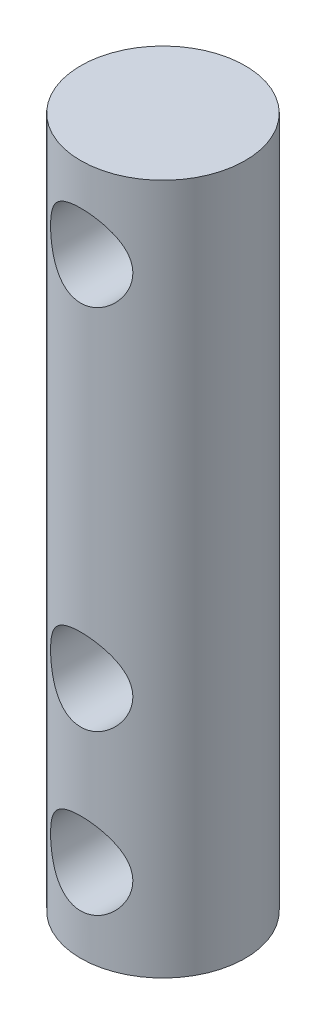
from build123d import *

# Parameters (mm, degrees)
SKETCH1_R               = 2.5
BOSS_EXTRUDE1_DEPTH     = 21
SKETCH2_R               = 1.25
CUT_EXTRUDE1_DEPTH      = 3.5
CUT_EXTRUDE1_DEPTH_BACK = 3.5


with BuildPart() as part:
    # Sketch1 → Boss-Extrude1 (new body)
    with BuildSketch(Plane(origin=(0, 0, 0), x_dir=(1, 0, 0), z_dir=(0, 1, 0))):
        Circle(SKETCH1_R)
    extrude(amount=BOSS_EXTRUDE1_DEPTH)

    # Sketch2 → Cut-Extrude1 (cut, two sides)
    with BuildSketch(Plane.XY) as cut_extrude1_sk:
        with Locations((0, 18.5)):
            Circle(SKETCH2_R)
        with Locations((0, 2.5)):
            Circle(SKETCH2_R)
        with Locations((0, 7.34)):
            Circle(SKETCH2_R)
    extrude(amount=CUT_EXTRUDE1_DEPTH, mode=Mode.SUBTRACT)
    extrude(cut_extrude1_sk.sketch, amount=-CUT_EXTRUDE1_DEPTH_BACK, mode=Mode.SUBTRACT)


solid = part.part
